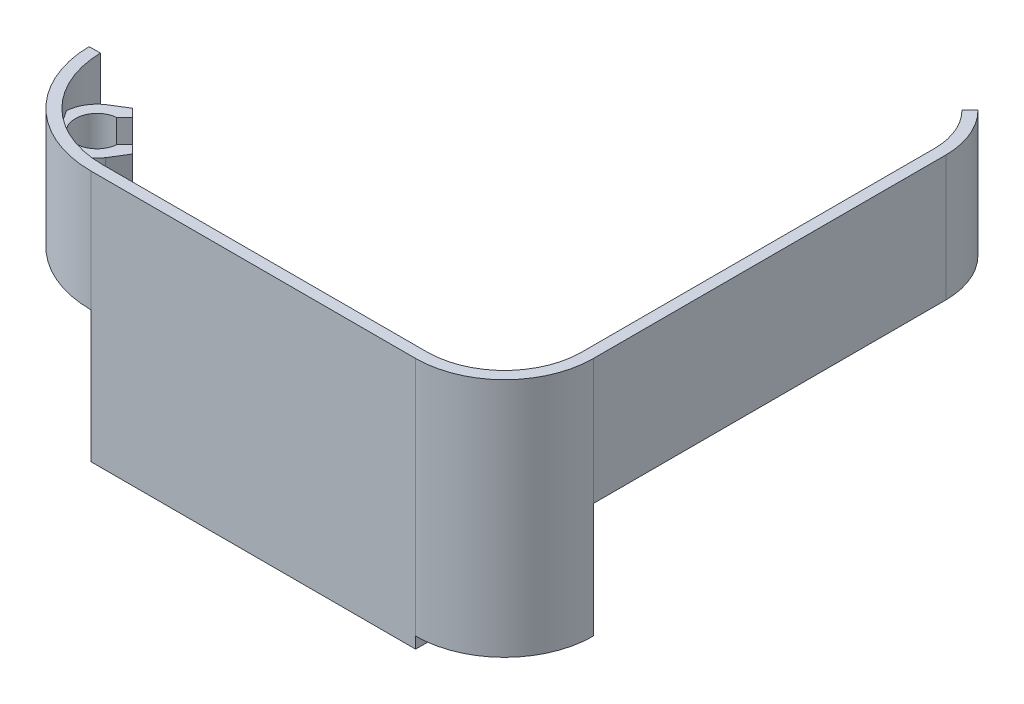
from build123d import *

# Parameters (mm, degrees)
EXTRUDE_THIN1_DEPTH = 53.975
BOSS_EXTRUDE1_START = 30.48
BOSS_EXTRUDE1_DEPTH = 19.05
SKETCH12_W          = 34.867415814
SKETCH12_H          = 30.456007234
CUT_EXTRUDE1_DEPTH  = 27.000736901
BOSS_EXTRUDE2_DEPTH = 28.194
SKETCH15_W          = 72.898
SKETCH15_H          = 6.35
BOSS_EXTRUDE3_DEPTH = 2.54


with BuildPart() as part:
    # Sketch8 → Extrude-Thin1 (new body)
    with BuildSketch(Plane(origin=(0, 0, 0), x_dir=(1, 0, 0), z_dir=(0, 1, 0))):
        with BuildLine():
            ThreePointArc((-21.840673053, -0.381230366), (-15.310661969, -15.580242811), (0, -21.844))
            Line((0, -21.844), (72.898, -21.844))
            ThreePointArc((72.898, -21.844), (85.209931142, -16.744231142), (90.3097, -4.4323))
            Line((90.3097, -4.4323), (92.8497, -4.4323))
            ThreePointArc((92.8497, -4.4323), (87.005982366, -18.540282366), (72.898, -24.384))
            Line((72.898, -24.384), (0, -24.384))
            ThreePointArc((0, -24.384), (-17.090971501, -17.391898952), (-24.380286199, -0.425559479))
            Line((-24.380286199, -0.425559479), (-21.840673053, -0.381230366))
        make_face()
    extrude(amount=EXTRUDE_THIN1_DEPTH)

    # Sketch10 → Boss-Extrude1 (add)
    with BuildSketch(Plane(origin=(0, 0, 0), x_dir=(1, 0, 0), z_dir=(0, 1, 0)).offset(BOSS_EXTRUDE1_START)):
        with BuildLine():
            Line((-6.641231784, -11.936352934), (-4.843541474, -10.138662625))
            Line((-4.843541474, -10.138662625), (-3.045851165, -11.936352934))
            Line((-3.045851165, -11.936352934), (-5.383859486, -15.696211745))
            ThreePointArc((-5.383859486, -15.696211745), (-7.807213542, -17.931410627), (-10.959862847, -18.895548216))
            ThreePointArc((-10.959862847, -18.895548216), (-15.446040528, -15.446040528), (-18.895548216, -10.959862847))
            ThreePointArc((-18.895548216, -10.959862847), (-17.931410627, -7.807213542), (-15.696211745, -5.383859486))
            Line((-15.696211745, -5.383859486), (-11.936352934, -3.045851165))
            Line((-11.936352934, -3.045851165), (-10.138662625, -4.843541474))
            Line((-10.138662625, -4.843541474), (-11.936352934, -6.641231784))
            ThreePointArc((-11.936352934, -6.641231784), (-14.946738288, -14.946738288), (-6.641231784, -11.936352934))
        make_face()
    extrude(amount=BOSS_EXTRUDE1_DEPTH)

    # Sketch12 → Cut-Extrude1 (cut, through all)
    with BuildSketch(Plane(origin=(0, 0, 0), x_dir=(-0.999847695, 0, 0.017452406), z_dir=(-0.017452406, 0, -0.999847695))):
        with Locations((17.814938273, 11.759496383)):
            Rectangle(SKETCH12_W, SKETCH12_H)
    extrude(amount=-CUT_EXTRUDE1_DEPTH, mode=Mode.SUBTRACT)

    # Sketch14 → Boss-Extrude2 (add)
    with BuildSketch(Plane(origin=(0, 53.975, 0), x_dir=(1, 0, 0), z_dir=(0, 1, 0))):
        with BuildLine():
            Line((85.945696481, 85.211636481), (87.741747705, 87.007687705))
            ThreePointArc((87.741747705, 87.007687705), (91.52218645, 81.349861294), (92.8497, 74.676))
            Line((92.8497, 74.676), (92.8497, -4.4323))
            Line((92.8497, -4.4323), (90.3097, -4.4323))
            Line((90.3097, -4.4323), (90.3097, 74.676))
            ThreePointArc((90.3097, 74.676), (89.175532438, 80.377845376), (85.945696481, 85.211636481))
        make_face()
    extrude(amount=-BOSS_EXTRUDE2_DEPTH)

    # Sketch15 → Boss-Extrude3 (add)
    with BuildSketch(Plane.XZ):
        with Locations((36.449, 21.209)):
            Rectangle(SKETCH15_W, SKETCH15_H)
    extrude(amount=BOSS_EXTRUDE3_DEPTH)


solid = part.part
